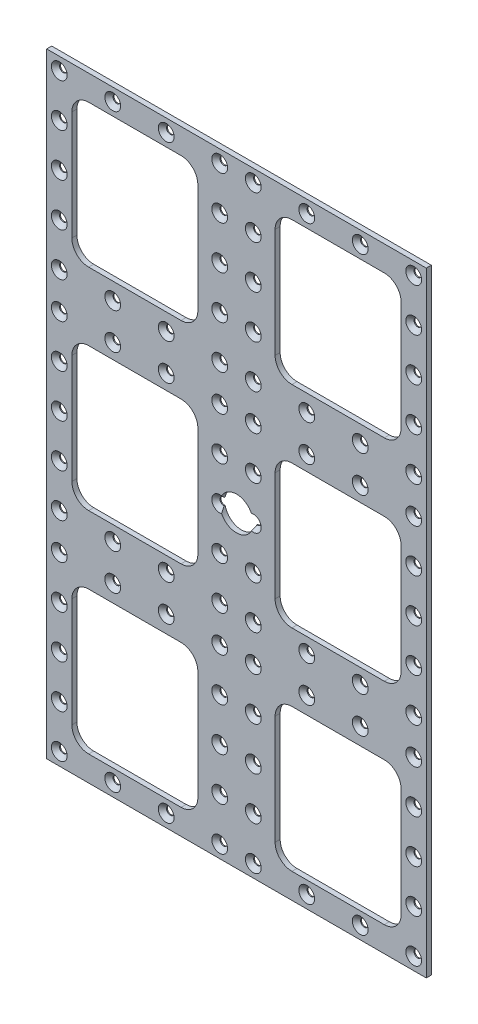
from build123d import *

# Parameters (mm, degrees)
SKETCH1_W              = 226
SKETCH1_H              = 366
BOSS_EXTRUDE1_DEPTH    = 3
SKETCH2_W              = 75
SKETCH2_H              = 85
CUT_EXTRUDE4_DEPTH     = 4
FILLET1_R              = 10
LPATTERN1_COUNT        = 3
LPATTERN1_PITCH        = 125.5
LPATTERN1_COUNT_DIR2   = 2
LPATTERN1_PITCH_DIR2   = 121
FILLET1_OF_LPATTERN1_R = 10
LPATTERN7_COUNT        = 4
LPATTERN7_PITCH        = 31.833333333
LPATTERN7_COUNT_DIR2   = 5
LPATTERN7_PITCH_DIR2   = 25.65625
LPATTERN8_COUNT        = 3
LPATTERN8_PITCH        = 124.1875
CUT_EXTRUDE5_REACH     = 5
SKETCH15_R             = 10


with BuildPart() as part:
    # Sketch1 → Boss-Extrude1 (new body)
    with BuildSketch(Plane.XY):
        Rectangle(SKETCH1_W, SKETCH1_H)
    extrude(amount=BOSS_EXTRUDE1_DEPTH)

    # Sketch2 → Cut-Extrude4 (cut, through all)
    with BuildSketch(Plane.XY):
        with Locations((-60.5, 125.5)):
            Rectangle(SKETCH2_W, SKETCH2_H)
    cut_extrude4 = extrude(amount=CUT_EXTRUDE4_DEPTH, mode=Mode.SUBTRACT)

    # Fillet1
    fillet1_edges = [part.edges().sort_by_distance(p)[0] for p in [
        (-23, 83, 1.5),
        (-23, 168, 1.5),
        (-98, 168, 1.5),
        (-98, 83, 1.5),
    ]]
    fillet(fillet1_edges, radius=FILLET1_R)

    # LPattern1: Cut-Extrude4 3 × 2
    with Locations(*[(j * LPATTERN1_PITCH_DIR2, -i * LPATTERN1_PITCH, 0) for i in range(LPATTERN1_COUNT) for j in range(LPATTERN1_COUNT_DIR2) if (i, j) != (0, 0)]):
        add(cut_extrude4, mode=Mode.SUBTRACT)

    # Fillet1 of LPattern1
    fillet1_of_lpattern1_edges = [part.edges().sort_by_distance(p)[0] for p in [
        (98, 83, 1.5),
        (98, 168, 1.5),
        (23, 168, 1.5),
        (23, 83, 1.5),
        (-23, -42.5, 1.5),
        (-23, 42.5, 1.5),
        (-98, 42.5, 1.5),
        (-98, -42.5, 1.5),
        (98, -42.5, 1.5),
        (98, 42.5, 1.5),
        (23, 42.5, 1.5),
        (23, -42.5, 1.5),
        (-23, -168, 1.5),
        (-23, -83, 1.5),
        (-98, -83, 1.5),
        (-98, -168, 1.5),
        (98, -168, 1.5),
        (98, -83, 1.5),
        (23, -83, 1.5),
        (23, -168, 1.5),
    ]]
    fillet(fillet1_of_lpattern1_edges, radius=FILLET1_OF_LPATTERN1_R)

    # Sketch13 → CSK for M4 Flat Head Machine Screw4 (revolve, cut)
    with BuildSketch(Plane(origin=(-105.5, 175.5, 3), x_dir=(0, -1, 0), z_dir=(1, 0, 0))):
        Polygon((0, 0), (0, 3), (2.25, 3), (2.25, 2.45), (4.7, 0), align=None)
    csk_for_m4_flat_head_machine_screw4 = revolve(axis=Axis((-105.5, 175.5, 9.35), (0, 0, -1)), mode=Mode.SUBTRACT)

    # LPattern7: CSK for M4 Flat Head Machine Screw4 4 × 5, 6 skipped
    with Locations(*[(i * LPATTERN7_PITCH, -j * LPATTERN7_PITCH_DIR2, 0) for i in range(LPATTERN7_COUNT) for j in range(LPATTERN7_COUNT_DIR2) if (i, j) not in ((0, 0), (1, 1), (1, 2), (1, 3), (2, 1), (2, 2), (2, 3))]):
        add(csk_for_m4_flat_head_machine_screw4, mode=Mode.SUBTRACT)

    # LPattern8: CSK for M4 Flat Head Machine Screw4 ×3
    with Locations(*[(0, -i * LPATTERN8_PITCH, 0) for i in range(1, LPATTERN8_COUNT)]):
        add(csk_for_m4_flat_head_machine_screw4, mode=Mode.SUBTRACT)

    # LPattern8 copy 1 sketch → LPattern8 copy 1 (revolve, cut)
    with BuildSketch(Plane(origin=(-105.5, 25.65625, 3), x_dir=(0, -1, 0), z_dir=(1, 0, 0))):
        Polygon((0, 0), (0, 3), (2.25, 3), (2.25, 2.45), (4.7, 0), align=None)
    revolve(axis=Axis((-105.5, 25.65625, 9.35), (0, 0, -1)), mode=Mode.SUBTRACT)

    # LPattern8 copy 2 sketch → LPattern8 copy 2 (revolve, cut)
    with BuildSketch(Plane(origin=(-105.5, -98.53125, 3), x_dir=(0, -1, 0), z_dir=(1, 0, 0))):
        Polygon((0, 0), (0, 3), (2.25, 3), (2.25, 2.45), (4.7, 0), align=None)
    revolve(axis=Axis((-105.5, -98.53125, 9.35), (0, 0, -1)), mode=Mode.SUBTRACT)

    # LPattern8 copy 3 sketch → LPattern8 copy 3 (revolve, cut)
    with BuildSketch(Plane(origin=(-105.5, 0, 3), x_dir=(0, -1, 0), z_dir=(1, 0, 0))):
        Polygon((0, 0), (0, 3), (2.25, 3), (2.25, 2.45), (4.7, 0), align=None)
    revolve(axis=Axis((-105.5, 0, 9.35), (0, 0, -1)), mode=Mode.SUBTRACT)

    # LPattern8 copy 4 sketch → LPattern8 copy 4 (revolve, cut)
    with BuildSketch(Plane(origin=(-105.5, -124.1875, 3), x_dir=(0, -1, 0), z_dir=(1, 0, 0))):
        Polygon((0, 0), (0, 3), (2.25, 3), (2.25, 2.45), (4.7, 0), align=None)
    revolve(axis=Axis((-105.5, -124.1875, 9.35), (0, 0, -1)), mode=Mode.SUBTRACT)

    # LPattern8 copy 5 sketch → LPattern8 copy 5 (revolve, cut)
    with BuildSketch(Plane(origin=(-105.5, -25.65625, 3), x_dir=(0, -1, 0), z_dir=(1, 0, 0))):
        Polygon((0, 0), (0, 3), (2.25, 3), (2.25, 2.45), (4.7, 0), align=None)
    revolve(axis=Axis((-105.5, -25.65625, 9.35), (0, 0, -1)), mode=Mode.SUBTRACT)

    # LPattern8 copy 6 sketch → LPattern8 copy 6 (revolve, cut)
    with BuildSketch(Plane(origin=(-105.5, -149.84375, 3), x_dir=(0, -1, 0), z_dir=(1, 0, 0))):
        Polygon((0, 0), (0, 3), (2.25, 3), (2.25, 2.45), (4.7, 0), align=None)
    revolve(axis=Axis((-105.5, -149.84375, 9.35), (0, 0, -1)), mode=Mode.SUBTRACT)

    # LPattern8 copy 7 sketch → LPattern8 copy 7 (revolve, cut)
    with BuildSketch(Plane(origin=(-105.5, -51.3125, 3), x_dir=(0, -1, 0), z_dir=(1, 0, 0))):
        Polygon((0, 0), (0, 3), (2.25, 3), (2.25, 2.45), (4.7, 0), align=None)
    revolve(axis=Axis((-105.5, -51.3125, 9.35), (0, 0, -1)), mode=Mode.SUBTRACT)

    # LPattern8 copy 8 sketch → LPattern8 copy 8 (revolve, cut)
    with BuildSketch(Plane(origin=(-105.5, -175.5, 3), x_dir=(0, -1, 0), z_dir=(1, 0, 0))):
        Polygon((0, 0), (0, 3), (2.25, 3), (2.25, 2.45), (4.7, 0), align=None)
    revolve(axis=Axis((-105.5, -175.5, 9.35), (0, 0, -1)), mode=Mode.SUBTRACT)

    # LPattern8 copy 9 sketch → LPattern8 copy 9 (revolve, cut)
    with BuildSketch(Plane(origin=(-73.666666667, 51.3125, 3), x_dir=(0, -1, 0), z_dir=(1, 0, 0))):
        Polygon((0, 0), (0, 3), (2.25, 3), (2.25, 2.45), (4.7, 0), align=None)
    revolve(axis=Axis((-73.666666667, 51.3125, 9.35), (0, 0, -1)), mode=Mode.SUBTRACT)

    # LPattern8 copy 10 sketch → LPattern8 copy 10 (revolve, cut)
    with BuildSketch(Plane(origin=(-73.666666667, -72.875, 3), x_dir=(0, -1, 0), z_dir=(1, 0, 0))):
        Polygon((0, 0), (0, 3), (2.25, 3), (2.25, 2.45), (4.7, 0), align=None)
    revolve(axis=Axis((-73.666666667, -72.875, 9.35), (0, 0, -1)), mode=Mode.SUBTRACT)

    # LPattern8 copy 11 sketch → LPattern8 copy 11 (revolve, cut)
    with BuildSketch(Plane(origin=(-73.666666667, -51.3125, 3), x_dir=(0, -1, 0), z_dir=(1, 0, 0))):
        Polygon((0, 0), (0, 3), (2.25, 3), (2.25, 2.45), (4.7, 0), align=None)
    revolve(axis=Axis((-73.666666667, -51.3125, 9.35), (0, 0, -1)), mode=Mode.SUBTRACT)

    # LPattern8 copy 12 sketch → LPattern8 copy 12 (revolve, cut)
    with BuildSketch(Plane(origin=(-73.666666667, -175.5, 3), x_dir=(0, -1, 0), z_dir=(1, 0, 0))):
        Polygon((0, 0), (0, 3), (2.25, 3), (2.25, 2.45), (4.7, 0), align=None)
    revolve(axis=Axis((-73.666666667, -175.5, 9.35), (0, 0, -1)), mode=Mode.SUBTRACT)

    # LPattern8 copy 13 sketch → LPattern8 copy 13 (revolve, cut)
    with BuildSketch(Plane(origin=(-41.833333333, 51.3125, 3), x_dir=(0, -1, 0), z_dir=(1, 0, 0))):
        Polygon((0, 0), (0, 3), (2.25, 3), (2.25, 2.45), (4.7, 0), align=None)
    revolve(axis=Axis((-41.833333333, 51.3125, 9.35), (0, 0, -1)), mode=Mode.SUBTRACT)

    # LPattern8 copy 14 sketch → LPattern8 copy 14 (revolve, cut)
    with BuildSketch(Plane(origin=(-41.833333333, -72.875, 3), x_dir=(0, -1, 0), z_dir=(1, 0, 0))):
        Polygon((0, 0), (0, 3), (2.25, 3), (2.25, 2.45), (4.7, 0), align=None)
    revolve(axis=Axis((-41.833333333, -72.875, 9.35), (0, 0, -1)), mode=Mode.SUBTRACT)

    # LPattern8 copy 15 sketch → LPattern8 copy 15 (revolve, cut)
    with BuildSketch(Plane(origin=(-41.833333333, -51.3125, 3), x_dir=(0, -1, 0), z_dir=(1, 0, 0))):
        Polygon((0, 0), (0, 3), (2.25, 3), (2.25, 2.45), (4.7, 0), align=None)
    revolve(axis=Axis((-41.833333333, -51.3125, 9.35), (0, 0, -1)), mode=Mode.SUBTRACT)

    # LPattern8 copy 16 sketch → LPattern8 copy 16 (revolve, cut)
    with BuildSketch(Plane(origin=(-41.833333333, -175.5, 3), x_dir=(0, -1, 0), z_dir=(1, 0, 0))):
        Polygon((0, 0), (0, 3), (2.25, 3), (2.25, 2.45), (4.7, 0), align=None)
    revolve(axis=Axis((-41.833333333, -175.5, 9.35), (0, 0, -1)), mode=Mode.SUBTRACT)

    # LPattern8 copy 17 sketch → LPattern8 copy 17 (revolve, cut)
    with BuildSketch(Plane(origin=(-10, 51.3125, 3), x_dir=(0, -1, 0), z_dir=(1, 0, 0))):
        Polygon((0, 0), (0, 3), (2.25, 3), (2.25, 2.45), (4.7, 0), align=None)
    revolve(axis=Axis((-10, 51.3125, 9.35), (0, 0, -1)), mode=Mode.SUBTRACT)

    # LPattern8 copy 18 sketch → LPattern8 copy 18 (revolve, cut)
    with BuildSketch(Plane(origin=(-10, -72.875, 3), x_dir=(0, -1, 0), z_dir=(1, 0, 0))):
        Polygon((0, 0), (0, 3), (2.25, 3), (2.25, 2.45), (4.7, 0), align=None)
    revolve(axis=Axis((-10, -72.875, 9.35), (0, 0, -1)), mode=Mode.SUBTRACT)

    # LPattern8 copy 19 sketch → LPattern8 copy 19 (revolve, cut)
    with BuildSketch(Plane(origin=(-10, 25.65625, 3), x_dir=(0, -1, 0), z_dir=(1, 0, 0))):
        Polygon((0, 0), (0, 3), (2.25, 3), (2.25, 2.45), (4.7, 0), align=None)
    revolve(axis=Axis((-10, 25.65625, 9.35), (0, 0, -1)), mode=Mode.SUBTRACT)

    # LPattern8 copy 20 sketch → LPattern8 copy 20 (revolve, cut)
    with BuildSketch(Plane(origin=(-10, -98.53125, 3), x_dir=(0, -1, 0), z_dir=(1, 0, 0))):
        Polygon((0, 0), (0, 3), (2.25, 3), (2.25, 2.45), (4.7, 0), align=None)
    revolve(axis=Axis((-10, -98.53125, 9.35), (0, 0, -1)), mode=Mode.SUBTRACT)

    # LPattern8 copy 21 sketch → LPattern8 copy 21 (revolve, cut)
    with BuildSketch(Plane(origin=(-10, 0, 3), x_dir=(0, -1, 0), z_dir=(1, 0, 0))):
        Polygon((0, 0), (0, 3), (2.25, 3), (2.25, 2.45), (4.7, 0), align=None)
    revolve(axis=Axis((-10, 0, 9.35), (0, 0, -1)), mode=Mode.SUBTRACT)

    # LPattern8 copy 22 sketch → LPattern8 copy 22 (revolve, cut)
    with BuildSketch(Plane(origin=(-10, -124.1875, 3), x_dir=(0, -1, 0), z_dir=(1, 0, 0))):
        Polygon((0, 0), (0, 3), (2.25, 3), (2.25, 2.45), (4.7, 0), align=None)
    revolve(axis=Axis((-10, -124.1875, 9.35), (0, 0, -1)), mode=Mode.SUBTRACT)

    # LPattern8 copy 23 sketch → LPattern8 copy 23 (revolve, cut)
    with BuildSketch(Plane(origin=(-10, -25.65625, 3), x_dir=(0, -1, 0), z_dir=(1, 0, 0))):
        Polygon((0, 0), (0, 3), (2.25, 3), (2.25, 2.45), (4.7, 0), align=None)
    revolve(axis=Axis((-10, -25.65625, 9.35), (0, 0, -1)), mode=Mode.SUBTRACT)

    # LPattern8 copy 24 sketch → LPattern8 copy 24 (revolve, cut)
    with BuildSketch(Plane(origin=(-10, -149.84375, 3), x_dir=(0, -1, 0), z_dir=(1, 0, 0))):
        Polygon((0, 0), (0, 3), (2.25, 3), (2.25, 2.45), (4.7, 0), align=None)
    revolve(axis=Axis((-10, -149.84375, 9.35), (0, 0, -1)), mode=Mode.SUBTRACT)

    # LPattern8 copy 25 sketch → LPattern8 copy 25 (revolve, cut)
    with BuildSketch(Plane(origin=(-10, -51.3125, 3), x_dir=(0, -1, 0), z_dir=(1, 0, 0))):
        Polygon((0, 0), (0, 3), (2.25, 3), (2.25, 2.45), (4.7, 0), align=None)
    revolve(axis=Axis((-10, -51.3125, 9.35), (0, 0, -1)), mode=Mode.SUBTRACT)

    # LPattern8 copy 26 sketch → LPattern8 copy 26 (revolve, cut)
    with BuildSketch(Plane(origin=(-10, -175.5, 3), x_dir=(0, -1, 0), z_dir=(1, 0, 0))):
        Polygon((0, 0), (0, 3), (2.25, 3), (2.25, 2.45), (4.7, 0), align=None)
    revolve(axis=Axis((-10, -175.5, 9.35), (0, 0, -1)), mode=Mode.SUBTRACT)

    # Mirror1: CSK for M4 Flat Head Machine Screw4 across plane
    add(csk_for_m4_flat_head_machine_screw4.mirror(Plane(origin=(0, 0, 0), x_dir=(0, 0, 1), z_dir=(1, 0, 0))), mode=Mode.SUBTRACT)

    # Mirror1 copy 1 sketch → Mirror1 copy 1 (revolve, cut)
    with BuildSketch(Plane(origin=(105.5, 51.3125, 3), x_dir=(0, -1, 0), z_dir=(-1, 0, 0))):
        Polygon((0, 0), (0, -3), (2.25, -3), (2.25, -2.45), (4.7, 0), align=None)
    revolve(axis=Axis((105.5, 51.3125, 9.35), (0, 0, 1)), mode=Mode.SUBTRACT)

    # Mirror1 copy 2 sketch → Mirror1 copy 2 (revolve, cut)
    with BuildSketch(Plane(origin=(105.5, -72.875, 3), x_dir=(0, -1, 0), z_dir=(-1, 0, 0))):
        Polygon((0, 0), (0, -3), (2.25, -3), (2.25, -2.45), (4.7, 0), align=None)
    revolve(axis=Axis((105.5, -72.875, 9.35), (0, 0, 1)), mode=Mode.SUBTRACT)

    # Mirror1 copy 3 sketch → Mirror1 copy 3 (revolve, cut)
    with BuildSketch(Plane(origin=(105.5, 25.65625, 3), x_dir=(0, -1, 0), z_dir=(-1, 0, 0))):
        Polygon((0, 0), (0, -3), (2.25, -3), (2.25, -2.45), (4.7, 0), align=None)
    revolve(axis=Axis((105.5, 25.65625, 9.35), (0, 0, 1)), mode=Mode.SUBTRACT)

    # Mirror1 copy 4 sketch → Mirror1 copy 4 (revolve, cut)
    with BuildSketch(Plane(origin=(105.5, -98.53125, 3), x_dir=(0, -1, 0), z_dir=(-1, 0, 0))):
        Polygon((0, 0), (0, -3), (2.25, -3), (2.25, -2.45), (4.7, 0), align=None)
    revolve(axis=Axis((105.5, -98.53125, 9.35), (0, 0, 1)), mode=Mode.SUBTRACT)

    # Mirror1 copy 5 sketch → Mirror1 copy 5 (revolve, cut)
    with BuildSketch(Plane(origin=(105.5, 0, 3), x_dir=(0, -1, 0), z_dir=(-1, 0, 0))):
        Polygon((0, 0), (0, -3), (2.25, -3), (2.25, -2.45), (4.7, 0), align=None)
    revolve(axis=Axis((105.5, 0, 9.35), (0, 0, 1)), mode=Mode.SUBTRACT)

    # Mirror1 copy 6 sketch → Mirror1 copy 6 (revolve, cut)
    with BuildSketch(Plane(origin=(105.5, -124.1875, 3), x_dir=(0, -1, 0), z_dir=(-1, 0, 0))):
        Polygon((0, 0), (0, -3), (2.25, -3), (2.25, -2.45), (4.7, 0), align=None)
    revolve(axis=Axis((105.5, -124.1875, 9.35), (0, 0, 1)), mode=Mode.SUBTRACT)

    # Mirror1 copy 7 sketch → Mirror1 copy 7 (revolve, cut)
    with BuildSketch(Plane(origin=(105.5, -25.65625, 3), x_dir=(0, -1, 0), z_dir=(-1, 0, 0))):
        Polygon((0, 0), (0, -3), (2.25, -3), (2.25, -2.45), (4.7, 0), align=None)
    revolve(axis=Axis((105.5, -25.65625, 9.35), (0, 0, 1)), mode=Mode.SUBTRACT)

    # Mirror1 copy 8 sketch → Mirror1 copy 8 (revolve, cut)
    with BuildSketch(Plane(origin=(105.5, -149.84375, 3), x_dir=(0, -1, 0), z_dir=(-1, 0, 0))):
        Polygon((0, 0), (0, -3), (2.25, -3), (2.25, -2.45), (4.7, 0), align=None)
    revolve(axis=Axis((105.5, -149.84375, 9.35), (0, 0, 1)), mode=Mode.SUBTRACT)

    # Mirror1 copy 9 sketch → Mirror1 copy 9 (revolve, cut)
    with BuildSketch(Plane(origin=(105.5, -51.3125, 3), x_dir=(0, -1, 0), z_dir=(-1, 0, 0))):
        Polygon((0, 0), (0, -3), (2.25, -3), (2.25, -2.45), (4.7, 0), align=None)
    revolve(axis=Axis((105.5, -51.3125, 9.35), (0, 0, 1)), mode=Mode.SUBTRACT)

    # Mirror1 copy 10 sketch → Mirror1 copy 10 (revolve, cut)
    with BuildSketch(Plane(origin=(105.5, -175.5, 3), x_dir=(0, -1, 0), z_dir=(-1, 0, 0))):
        Polygon((0, 0), (0, -3), (2.25, -3), (2.25, -2.45), (4.7, 0), align=None)
    revolve(axis=Axis((105.5, -175.5, 9.35), (0, 0, 1)), mode=Mode.SUBTRACT)

    # Mirror1 copy 11 sketch → Mirror1 copy 11 (revolve, cut)
    with BuildSketch(Plane(origin=(73.666666667, 51.3125, 3), x_dir=(0, -1, 0), z_dir=(-1, 0, 0))):
        Polygon((0, 0), (0, -3), (2.25, -3), (2.25, -2.45), (4.7, 0), align=None)
    revolve(axis=Axis((73.666666667, 51.3125, 9.35), (0, 0, 1)), mode=Mode.SUBTRACT)

    # Mirror1 copy 12 sketch → Mirror1 copy 12 (revolve, cut)
    with BuildSketch(Plane(origin=(73.666666667, -72.875, 3), x_dir=(0, -1, 0), z_dir=(-1, 0, 0))):
        Polygon((0, 0), (0, -3), (2.25, -3), (2.25, -2.45), (4.7, 0), align=None)
    revolve(axis=Axis((73.666666667, -72.875, 9.35), (0, 0, 1)), mode=Mode.SUBTRACT)

    # Mirror1 copy 13 sketch → Mirror1 copy 13 (revolve, cut)
    with BuildSketch(Plane(origin=(73.666666667, -51.3125, 3), x_dir=(0, -1, 0), z_dir=(-1, 0, 0))):
        Polygon((0, 0), (0, -3), (2.25, -3), (2.25, -2.45), (4.7, 0), align=None)
    revolve(axis=Axis((73.666666667, -51.3125, 9.35), (0, 0, 1)), mode=Mode.SUBTRACT)

    # Mirror1 copy 14 sketch → Mirror1 copy 14 (revolve, cut)
    with BuildSketch(Plane(origin=(73.666666667, -175.5, 3), x_dir=(0, -1, 0), z_dir=(-1, 0, 0))):
        Polygon((0, 0), (0, -3), (2.25, -3), (2.25, -2.45), (4.7, 0), align=None)
    revolve(axis=Axis((73.666666667, -175.5, 9.35), (0, 0, 1)), mode=Mode.SUBTRACT)

    # Mirror1 copy 15 sketch → Mirror1 copy 15 (revolve, cut)
    with BuildSketch(Plane(origin=(41.833333333, 51.3125, 3), x_dir=(0, -1, 0), z_dir=(-1, 0, 0))):
        Polygon((0, 0), (0, -3), (2.25, -3), (2.25, -2.45), (4.7, 0), align=None)
    revolve(axis=Axis((41.833333333, 51.3125, 9.35), (0, 0, 1)), mode=Mode.SUBTRACT)

    # Mirror1 copy 16 sketch → Mirror1 copy 16 (revolve, cut)
    with BuildSketch(Plane(origin=(41.833333333, -72.875, 3), x_dir=(0, -1, 0), z_dir=(-1, 0, 0))):
        Polygon((0, 0), (0, -3), (2.25, -3), (2.25, -2.45), (4.7, 0), align=None)
    revolve(axis=Axis((41.833333333, -72.875, 9.35), (0, 0, 1)), mode=Mode.SUBTRACT)

    # Mirror1 copy 17 sketch → Mirror1 copy 17 (revolve, cut)
    with BuildSketch(Plane(origin=(41.833333333, -51.3125, 3), x_dir=(0, -1, 0), z_dir=(-1, 0, 0))):
        Polygon((0, 0), (0, -3), (2.25, -3), (2.25, -2.45), (4.7, 0), align=None)
    revolve(axis=Axis((41.833333333, -51.3125, 9.35), (0, 0, 1)), mode=Mode.SUBTRACT)

    # Mirror1 copy 18 sketch → Mirror1 copy 18 (revolve, cut)
    with BuildSketch(Plane(origin=(41.833333333, -175.5, 3), x_dir=(0, -1, 0), z_dir=(-1, 0, 0))):
        Polygon((0, 0), (0, -3), (2.25, -3), (2.25, -2.45), (4.7, 0), align=None)
    revolve(axis=Axis((41.833333333, -175.5, 9.35), (0, 0, 1)), mode=Mode.SUBTRACT)

    # Mirror1 copy 19 sketch → Mirror1 copy 19 (revolve, cut)
    with BuildSketch(Plane(origin=(10, 51.3125, 3), x_dir=(0, -1, 0), z_dir=(-1, 0, 0))):
        Polygon((0, 0), (0, -3), (2.25, -3), (2.25, -2.45), (4.7, 0), align=None)
    revolve(axis=Axis((10, 51.3125, 9.35), (0, 0, 1)), mode=Mode.SUBTRACT)

    # Mirror1 copy 20 sketch → Mirror1 copy 20 (revolve, cut)
    with BuildSketch(Plane(origin=(10, -72.875, 3), x_dir=(0, -1, 0), z_dir=(-1, 0, 0))):
        Polygon((0, 0), (0, -3), (2.25, -3), (2.25, -2.45), (4.7, 0), align=None)
    revolve(axis=Axis((10, -72.875, 9.35), (0, 0, 1)), mode=Mode.SUBTRACT)

    # Mirror1 copy 21 sketch → Mirror1 copy 21 (revolve, cut)
    with BuildSketch(Plane(origin=(10, 25.65625, 3), x_dir=(0, -1, 0), z_dir=(-1, 0, 0))):
        Polygon((0, 0), (0, -3), (2.25, -3), (2.25, -2.45), (4.7, 0), align=None)
    revolve(axis=Axis((10, 25.65625, 9.35), (0, 0, 1)), mode=Mode.SUBTRACT)

    # Mirror1 copy 22 sketch → Mirror1 copy 22 (revolve, cut)
    with BuildSketch(Plane(origin=(10, -98.53125, 3), x_dir=(0, -1, 0), z_dir=(-1, 0, 0))):
        Polygon((0, 0), (0, -3), (2.25, -3), (2.25, -2.45), (4.7, 0), align=None)
    revolve(axis=Axis((10, -98.53125, 9.35), (0, 0, 1)), mode=Mode.SUBTRACT)

    # Mirror1 copy 23 sketch → Mirror1 copy 23 (revolve, cut)
    with BuildSketch(Plane(origin=(10, 0, 3), x_dir=(0, -1, 0), z_dir=(-1, 0, 0))):
        Polygon((0, 0), (0, -3), (2.25, -3), (2.25, -2.45), (4.7, 0), align=None)
    revolve(axis=Axis((10, 0, 9.35), (0, 0, 1)), mode=Mode.SUBTRACT)

    # Mirror1 copy 24 sketch → Mirror1 copy 24 (revolve, cut)
    with BuildSketch(Plane(origin=(10, -124.1875, 3), x_dir=(0, -1, 0), z_dir=(-1, 0, 0))):
        Polygon((0, 0), (0, -3), (2.25, -3), (2.25, -2.45), (4.7, 0), align=None)
    revolve(axis=Axis((10, -124.1875, 9.35), (0, 0, 1)), mode=Mode.SUBTRACT)

    # Mirror1 copy 25 sketch → Mirror1 copy 25 (revolve, cut)
    with BuildSketch(Plane(origin=(10, -25.65625, 3), x_dir=(0, -1, 0), z_dir=(-1, 0, 0))):
        Polygon((0, 0), (0, -3), (2.25, -3), (2.25, -2.45), (4.7, 0), align=None)
    revolve(axis=Axis((10, -25.65625, 9.35), (0, 0, 1)), mode=Mode.SUBTRACT)

    # Mirror1 copy 26 sketch → Mirror1 copy 26 (revolve, cut)
    with BuildSketch(Plane(origin=(10, -149.84375, 3), x_dir=(0, -1, 0), z_dir=(-1, 0, 0))):
        Polygon((0, 0), (0, -3), (2.25, -3), (2.25, -2.45), (4.7, 0), align=None)
    revolve(axis=Axis((10, -149.84375, 9.35), (0, 0, 1)), mode=Mode.SUBTRACT)

    # Mirror1 copy 27 sketch → Mirror1 copy 27 (revolve, cut)
    with BuildSketch(Plane(origin=(10, -51.3125, 3), x_dir=(0, -1, 0), z_dir=(-1, 0, 0))):
        Polygon((0, 0), (0, -3), (2.25, -3), (2.25, -2.45), (4.7, 0), align=None)
    revolve(axis=Axis((10, -51.3125, 9.35), (0, 0, 1)), mode=Mode.SUBTRACT)

    # Mirror1 copy 28 sketch → Mirror1 copy 28 (revolve, cut)
    with BuildSketch(Plane(origin=(10, -175.5, 3), x_dir=(0, -1, 0), z_dir=(-1, 0, 0))):
        Polygon((0, 0), (0, -3), (2.25, -3), (2.25, -2.45), (4.7, 0), align=None)
    revolve(axis=Axis((10, -175.5, 9.35), (0, 0, 1)), mode=Mode.SUBTRACT)

    # Mirror1 copy 29 sketch → Mirror1 copy 29 (revolve, cut)
    with BuildSketch(Plane(origin=(105.5, 149.84375, 3), x_dir=(0, -1, 0), z_dir=(-1, 0, 0))):
        Polygon((0, 0), (0, -3), (2.25, -3), (2.25, -2.45), (4.7, 0), align=None)
    revolve(axis=Axis((105.5, 149.84375, 9.35), (0, 0, 1)), mode=Mode.SUBTRACT)

    # Mirror1 copy 30 sketch → Mirror1 copy 30 (revolve, cut)
    with BuildSketch(Plane(origin=(105.5, 124.1875, 3), x_dir=(0, -1, 0), z_dir=(-1, 0, 0))):
        Polygon((0, 0), (0, -3), (2.25, -3), (2.25, -2.45), (4.7, 0), align=None)
    revolve(axis=Axis((105.5, 124.1875, 9.35), (0, 0, 1)), mode=Mode.SUBTRACT)

    # Mirror1 copy 31 sketch → Mirror1 copy 31 (revolve, cut)
    with BuildSketch(Plane(origin=(105.5, 98.53125, 3), x_dir=(0, -1, 0), z_dir=(-1, 0, 0))):
        Polygon((0, 0), (0, -3), (2.25, -3), (2.25, -2.45), (4.7, 0), align=None)
    revolve(axis=Axis((105.5, 98.53125, 9.35), (0, 0, 1)), mode=Mode.SUBTRACT)

    # Mirror1 copy 32 sketch → Mirror1 copy 32 (revolve, cut)
    with BuildSketch(Plane(origin=(105.5, 72.875, 3), x_dir=(0, -1, 0), z_dir=(-1, 0, 0))):
        Polygon((0, 0), (0, -3), (2.25, -3), (2.25, -2.45), (4.7, 0), align=None)
    revolve(axis=Axis((105.5, 72.875, 9.35), (0, 0, 1)), mode=Mode.SUBTRACT)

    # Mirror1 copy 33 sketch → Mirror1 copy 33 (revolve, cut)
    with BuildSketch(Plane(origin=(73.666666667, 175.5, 3), x_dir=(0, -1, 0), z_dir=(-1, 0, 0))):
        Polygon((0, 0), (0, -3), (2.25, -3), (2.25, -2.45), (4.7, 0), align=None)
    revolve(axis=Axis((73.666666667, 175.5, 9.35), (0, 0, 1)), mode=Mode.SUBTRACT)

    # Mirror1 copy 34 sketch → Mirror1 copy 34 (revolve, cut)
    with BuildSketch(Plane(origin=(73.666666667, 72.875, 3), x_dir=(0, -1, 0), z_dir=(-1, 0, 0))):
        Polygon((0, 0), (0, -3), (2.25, -3), (2.25, -2.45), (4.7, 0), align=None)
    revolve(axis=Axis((73.666666667, 72.875, 9.35), (0, 0, 1)), mode=Mode.SUBTRACT)

    # Mirror1 copy 35 sketch → Mirror1 copy 35 (revolve, cut)
    with BuildSketch(Plane(origin=(41.833333333, 175.5, 3), x_dir=(0, -1, 0), z_dir=(-1, 0, 0))):
        Polygon((0, 0), (0, -3), (2.25, -3), (2.25, -2.45), (4.7, 0), align=None)
    revolve(axis=Axis((41.833333333, 175.5, 9.35), (0, 0, 1)), mode=Mode.SUBTRACT)

    # Mirror1 copy 36 sketch → Mirror1 copy 36 (revolve, cut)
    with BuildSketch(Plane(origin=(41.833333333, 72.875, 3), x_dir=(0, -1, 0), z_dir=(-1, 0, 0))):
        Polygon((0, 0), (0, -3), (2.25, -3), (2.25, -2.45), (4.7, 0), align=None)
    revolve(axis=Axis((41.833333333, 72.875, 9.35), (0, 0, 1)), mode=Mode.SUBTRACT)

    # Mirror1 copy 37 sketch → Mirror1 copy 37 (revolve, cut)
    with BuildSketch(Plane(origin=(10, 175.5, 3), x_dir=(0, -1, 0), z_dir=(-1, 0, 0))):
        Polygon((0, 0), (0, -3), (2.25, -3), (2.25, -2.45), (4.7, 0), align=None)
    revolve(axis=Axis((10, 175.5, 9.35), (0, 0, 1)), mode=Mode.SUBTRACT)

    # Mirror1 copy 38 sketch → Mirror1 copy 38 (revolve, cut)
    with BuildSketch(Plane(origin=(10, 149.84375, 3), x_dir=(0, -1, 0), z_dir=(-1, 0, 0))):
        Polygon((0, 0), (0, -3), (2.25, -3), (2.25, -2.45), (4.7, 0), align=None)
    revolve(axis=Axis((10, 149.84375, 9.35), (0, 0, 1)), mode=Mode.SUBTRACT)

    # Mirror1 copy 39 sketch → Mirror1 copy 39 (revolve, cut)
    with BuildSketch(Plane(origin=(10, 124.1875, 3), x_dir=(0, -1, 0), z_dir=(-1, 0, 0))):
        Polygon((0, 0), (0, -3), (2.25, -3), (2.25, -2.45), (4.7, 0), align=None)
    revolve(axis=Axis((10, 124.1875, 9.35), (0, 0, 1)), mode=Mode.SUBTRACT)

    # Mirror1 copy 40 sketch → Mirror1 copy 40 (revolve, cut)
    with BuildSketch(Plane(origin=(10, 98.53125, 3), x_dir=(0, -1, 0), z_dir=(-1, 0, 0))):
        Polygon((0, 0), (0, -3), (2.25, -3), (2.25, -2.45), (4.7, 0), align=None)
    revolve(axis=Axis((10, 98.53125, 9.35), (0, 0, 1)), mode=Mode.SUBTRACT)

    # Mirror1 copy 41 sketch → Mirror1 copy 41 (revolve, cut)
    with BuildSketch(Plane(origin=(10, 72.875, 3), x_dir=(0, -1, 0), z_dir=(-1, 0, 0))):
        Polygon((0, 0), (0, -3), (2.25, -3), (2.25, -2.45), (4.7, 0), align=None)
    revolve(axis=Axis((10, 72.875, 9.35), (0, 0, 1)), mode=Mode.SUBTRACT)

    # Sketch15 → Cut-Extrude5 (cut, up to next)
    with BuildSketch(Plane.XY.offset(3), mode=Mode.PRIVATE) as cut_extrude5_sk1:
        Circle(SKETCH15_R)
    cut_extrude5_tool1 = extrude(cut_extrude5_sk1.sketch, amount=-CUT_EXTRUDE5_REACH, mode=Mode.PRIVATE) & part.part
    add(cut_extrude5_tool1.solids().sort_by_distance((0, 0, 3))[0], mode=Mode.SUBTRACT)


solid = part.part
